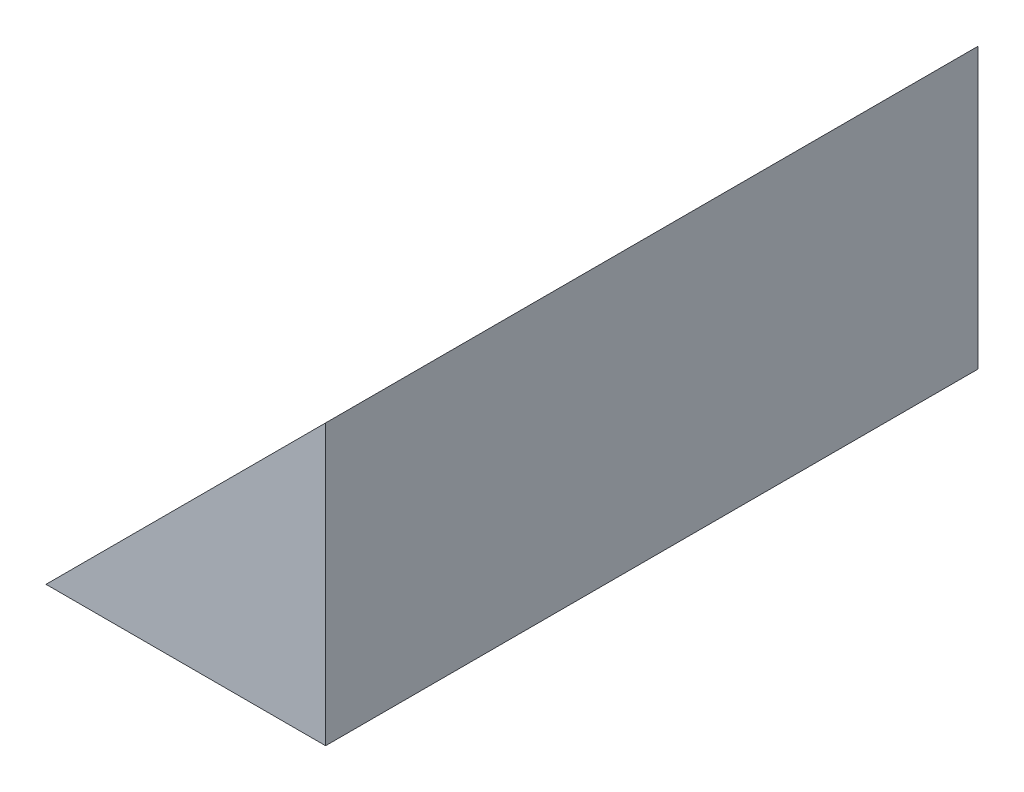
from build123d import *

# Parameters (mm, degrees)
SKETCH1_W           = 38.1
SKETCH1_H           = 88.9
BOSS_EXTRUDE1_DEPTH = 38.1
CUT_EXTRUDE1_DEPTH  = 89.9


with BuildPart() as part:
    # Sketch1 → Boss-Extrude1 (new body)
    with BuildSketch(Plane(origin=(0, 0, 0), x_dir=(1, 0, 0), z_dir=(0, 1, 0))):
        with Locations((19.05, 44.45)):
            Rectangle(SKETCH1_W, SKETCH1_H)
    extrude(amount=BOSS_EXTRUDE1_DEPTH)

    # Sketch2 → Cut-Extrude1 (cut, through all)
    with BuildSketch(Plane.XY):
        Polygon((0, 0), (38.1, 38.1), (0, 38.1), align=None)
    extrude(amount=-CUT_EXTRUDE1_DEPTH, mode=Mode.SUBTRACT)


solid = part.part
